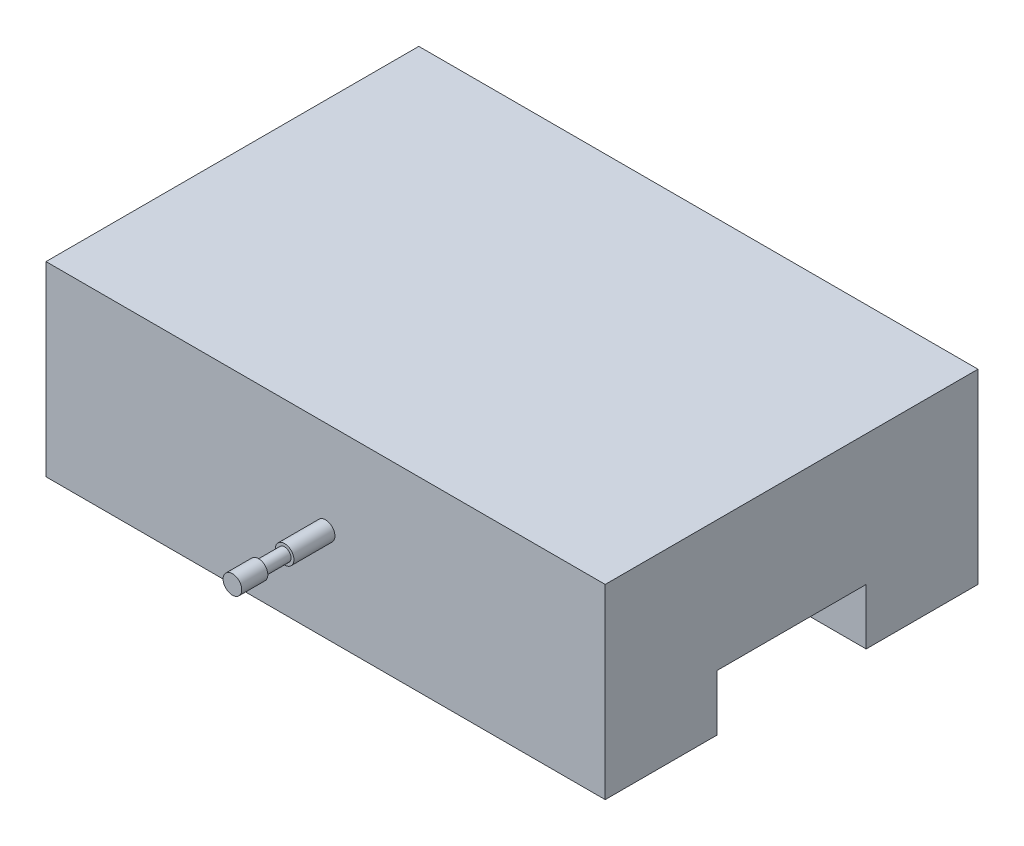
from build123d import *

# Parameters (mm, degrees)
BOSS_EXTRUDE1_DEPTH = 150
SKETCH2_R           = 2.5
BOSS_EXTRUDE2_DEPTH = 25
CUT_EXTRUDE1_START  = -7
SKETCH3_R           = 2.5
SKETCH3_R_2         = 1.733910687
CUT_EXTRUDE1_DEPTH  = 7


with BuildPart() as part:
    # Sketch1 → Boss-Extrude1 (new body)
    with BuildSketch(Plane(origin=(0, 0, 0), x_dir=(0, 0, -1), z_dir=(1, 0, 0))):
        Polygon((-50, 35), (50, 35), (50, -15), (20, -15), (20, 0), (-20, 0), (-20, -15), (-50, -15), align=None)
    extrude(amount=-BOSS_EXTRUDE1_DEPTH)

    # Sketch2 → Boss-Extrude2 (add)
    with BuildSketch(Plane.XY.offset(50)):
        with Locations((-75, 10)):
            Circle(SKETCH2_R)
    extrude(amount=BOSS_EXTRUDE2_DEPTH)

    # Sketch3 → Cut-Extrude1 (cut)
    with BuildSketch(Plane.XY.offset(75).offset(CUT_EXTRUDE1_START)):
        with Locations((-75, 10)):
            Circle(SKETCH3_R)
        with Locations((-75, 10)):
            Circle(SKETCH3_R_2, mode=Mode.SUBTRACT)
    extrude(amount=-CUT_EXTRUDE1_DEPTH, mode=Mode.SUBTRACT)


solid = part.part
